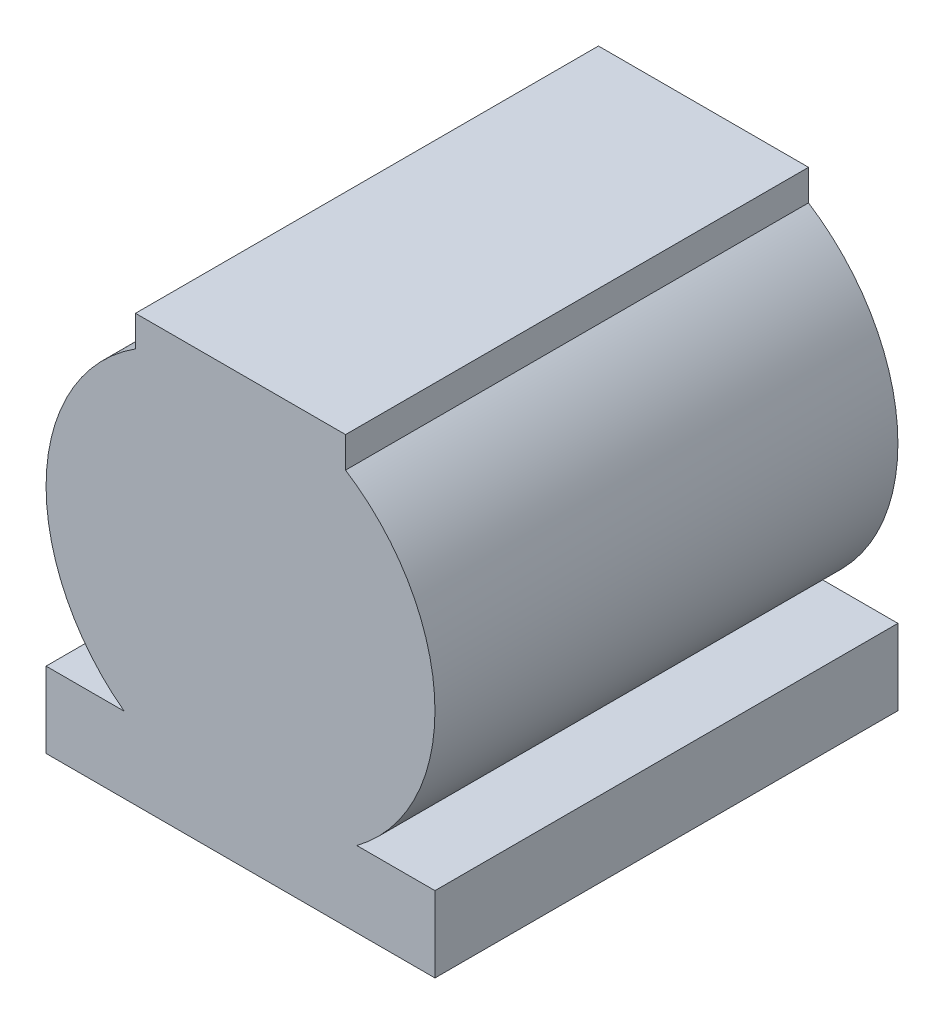
from build123d import *

# Parameters (mm, degrees)
SKETCH_1_W               = 105
SKETCH_1_H               = 125
EXTRUDE_1_DEPTH          = 115
CUT_EXTRUDE_1_DEPTH      = 1
CUT_EXTRUDE_1_DEPTH_BACK = 126


with BuildPart() as part:
    # Эскиз1 → Бобышка-Вытянуть1 (new body)
    with BuildSketch(Plane(origin=(0, 0, 0), x_dir=(1, 0, 0), z_dir=(0, 1, 0))):
        Rectangle(SKETCH_1_W, SKETCH_1_H)
    extrude(amount=EXTRUDE_1_DEPTH)

    # Эскиз2 → Вырез-Вытянуть1 (cut, two sides)
    with BuildSketch(Plane.XY.offset(62.5)) as cut_extrude_1_sk:
        with BuildLine():
            ThreePointArc((-52.5, 62.5), (-46.071684117, 87.67240399), (-28.360955327, 106.680382671))
            Line((-28.360955327, 106.680382671), (-28.360955327, 115))
            Line((-28.360955327, 115), (-52.5, 115))
            Line((-52.5, 115), (-52.5, 62.5))
        make_face()
        with BuildLine():
            ThreePointArc((-31.408561264, 20.43157622), (-46.931862665, 38.970225951), (-52.5, 62.5))
            Line((-52.5, 62.5), (-52.5, 20.43157622))
            Line((-52.5, 20.43157622), (-31.408561264, 20.43157622))
        make_face()
        with BuildLine():
            Line((52.5, 20.43157622), (52.5, 62.499999878))
            ThreePointArc((52.5, 62.499999878), (46.931862637, 38.970225896), (31.408561264, 20.43157622))
            Line((31.408561264, 20.43157622), (52.5, 20.43157622))
        make_face()
        with BuildLine():
            Line((52.5, 115), (28.360955327, 115))
            Line((28.360955327, 115), (28.360955327, 106.680382671))
            ThreePointArc((28.360955327, 106.680382671), (46.071684146, 87.672403937), (52.5, 62.499999878))
            Line((52.5, 62.499999878), (52.5, 115))
        make_face()
    extrude(amount=CUT_EXTRUDE_1_DEPTH, mode=Mode.SUBTRACT)
    extrude(cut_extrude_1_sk.sketch, amount=-CUT_EXTRUDE_1_DEPTH_BACK, mode=Mode.SUBTRACT)


solid = part.part
